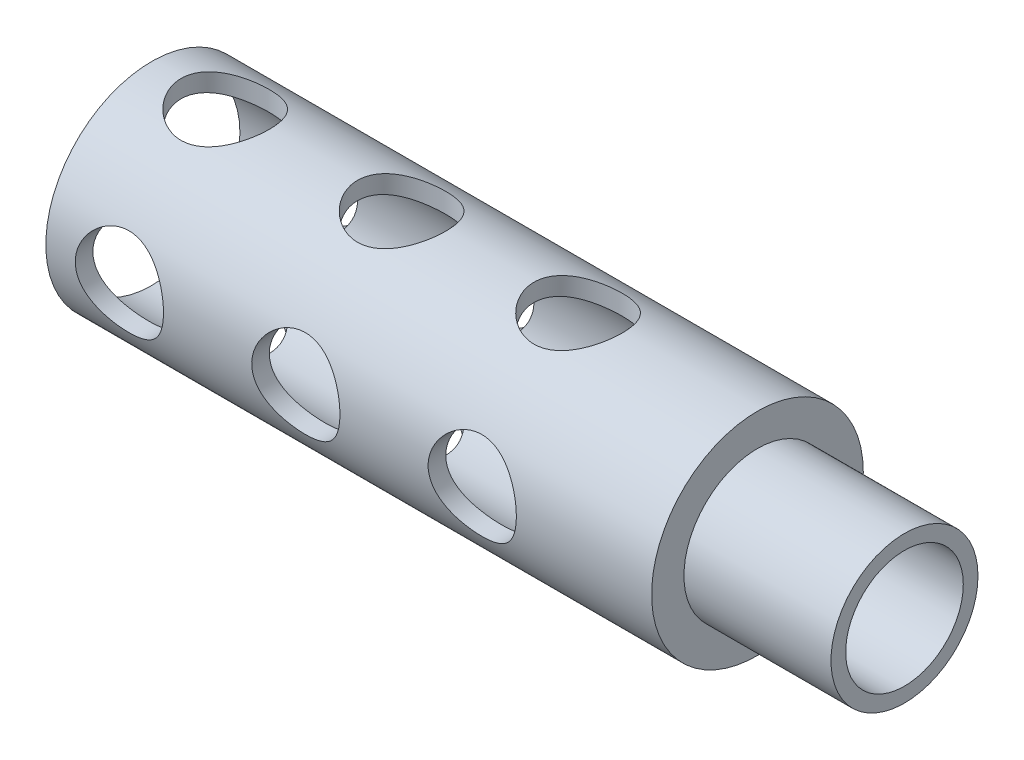
from build123d import *

# Parameters (mm, degrees)
SKETCH1_R           = 11.43
SKETCH1_R_2         = 6.35
BOSS_EXTRUDE1_DEPTH = 81.28
SKETCH5_R           = 9.525
CUT_EXTRUDE4_DEPTH  = 57.15
SKETCH2_R           = 11.43
SKETCH2_R_2         = 7.9375
CUT_EXTRUDE1_DEPTH  = 15.875
SKETCH3_R           = 4.7625
CUT_EXTRUDE2_DEPTH  = 90.964060602
LPATTERN1_COUNT     = 3
LPATTERN1_PITCH     = 19.05
SKETCH4_R           = 4.7625
CUT_EXTRUDE3_DEPTH  = 90.964060746
LPATTERN2_COUNT     = 3
LPATTERN2_PITCH     = 19.05


with BuildPart() as part:
    # Sketch1 → Boss-Extrude1 (new body)
    with BuildSketch(Plane(origin=(0, 0, 0), x_dir=(0, 0, -1), z_dir=(1, 0, 0))):
        Circle(SKETCH1_R)
        Circle(SKETCH1_R_2, mode=Mode.SUBTRACT)
    extrude(amount=-BOSS_EXTRUDE1_DEPTH)

    # Sketch5 → Cut-Extrude4 (cut)
    with BuildSketch(Plane.ZY.offset(81.28)):
        Circle(SKETCH5_R)
    extrude(amount=-CUT_EXTRUDE4_DEPTH, mode=Mode.SUBTRACT)

    # Sketch2 → Cut-Extrude1 (cut)
    with BuildSketch(Plane(origin=(0, 0, 0), x_dir=(0, 0, -1), z_dir=(1, 0, 0))):
        Circle(SKETCH2_R)
        Circle(SKETCH2_R_2, mode=Mode.SUBTRACT)
    extrude(amount=-CUT_EXTRUDE1_DEPTH, mode=Mode.SUBTRACT)

    # Sketch3 → Cut-Extrude2 (cut, through all)
    with BuildSketch(Plane(origin=(0, 25.4, 0), x_dir=(-1, 0, 0), z_dir=(0, 1, 0))):
        with Locations((73.3425, 0)):
            Circle(SKETCH3_R)
    cut_extrude2 = extrude(amount=-CUT_EXTRUDE2_DEPTH, mode=Mode.SUBTRACT)

    # LPattern1: Cut-Extrude2 ×3
    with Locations(*[(i * LPATTERN1_PITCH, 0, 0) for i in range(1, LPATTERN1_COUNT)]):
        add(cut_extrude2, mode=Mode.SUBTRACT)

    # Sketch4 → Cut-Extrude3 (cut, through all)
    with BuildSketch(Plane.XY.offset(25.4)):
        with Locations((-73.3425, 0)):
            Circle(SKETCH4_R)
    cut_extrude3 = extrude(amount=-CUT_EXTRUDE3_DEPTH, mode=Mode.SUBTRACT)

    # LPattern2: Cut-Extrude3 ×3
    with Locations(*[(i * LPATTERN2_PITCH, 0, 0) for i in range(1, LPATTERN2_COUNT)]):
        add(cut_extrude3, mode=Mode.SUBTRACT)


solid = part.part
